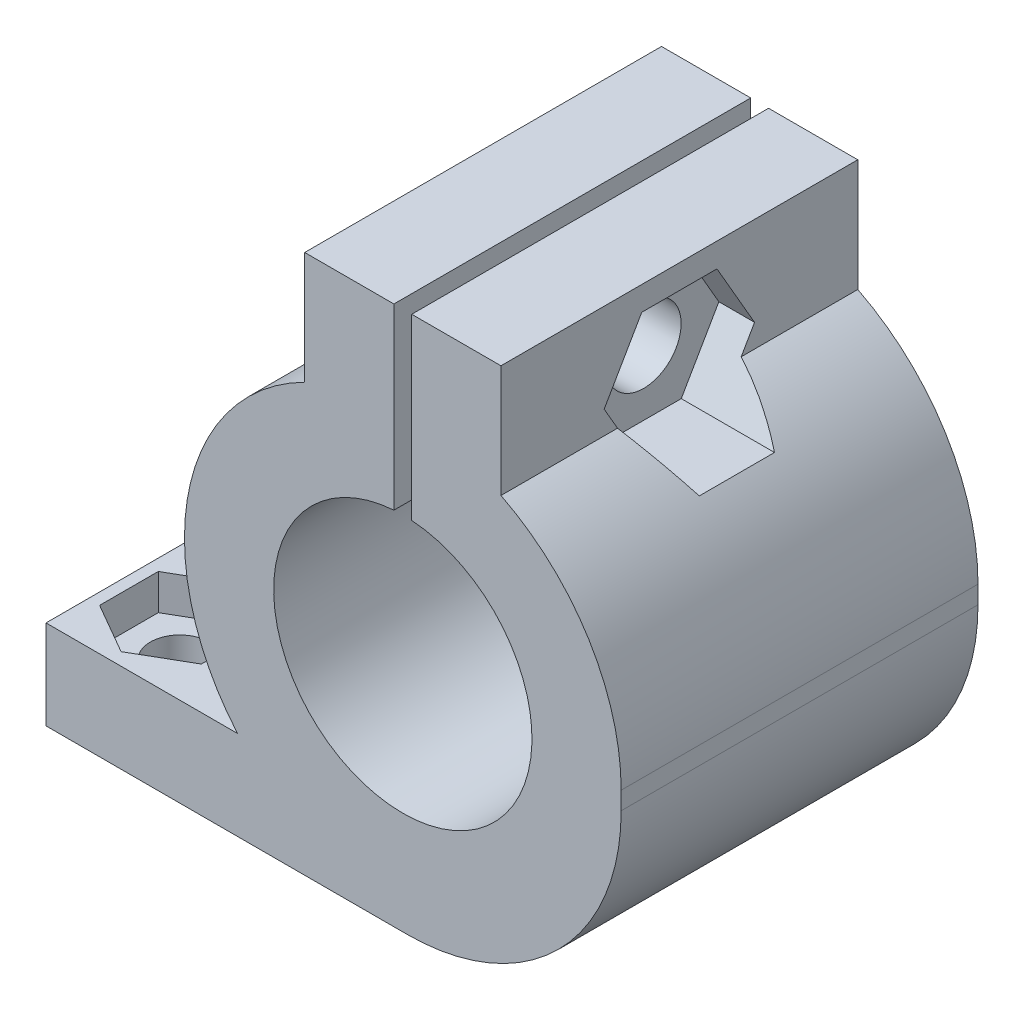
from build123d import *

# Parameters (mm, degrees)
BOSS_EXTRUDE1_DEPTH     = 20
SKETCH2_R               = 2.1
CUT_EXTRUDE1_DEPTH      = 15.5
CUT_EXTRUDE1_DEPTH_BACK = 18.739
SKETCH4_R               = 3.65
CUT_EXTRUDE2_DEPTH      = 15.5
CUT_EXTRUDE2_DEPTH_BACK = 2
CUT_EXTRUDE3_DEPTH      = 7.7390001
CUT_EXTRUDE3_DEPTH_BACK = 2
SKETCH6_R               = 1.65
CUT_EXTRUDE4_DEPTH      = 6
CUT_EXTRUDE5_DEPTH      = 2
FILLET1_R               = 12


with BuildPart() as part:
    # Sketch1 → Boss-Extrude1 (new body)
    with BuildSketch(Plane.XY):
        with BuildLine():
            Line((-0.5, 7.221711778), (-0.5, 17.231747474))
            Line((-0.5, 17.231747474), (-5.5, 17.231747474))
            Line((-5.5, 17.231747474), (-5.5, 10.933577685))
            ThreePointArc((-5.5, 10.933577685), (-12.004275475, 2.385475074), (-9.262457611, -8))
            Line((-9.262457611, -8), (-20, -8))
            Line((-20, -8), (-20, -13))
            Line((-20, -13), (12.239, -13))
            Line((12.239, -13), (12.239, 0))
            ThreePointArc((12.239, 0), (10.418915994, 6.421784059), (5.5, 10.933577685))
            Line((5.5, 10.933577685), (5.5, 17.231747474))
            Line((5.5, 17.231747474), (0.5, 17.231747474))
            Line((0.5, 17.231747474), (0.5, 7.221711778))
            ThreePointArc((0.5, 7.221711778), (0, -7.239), (-0.5, 7.221711778))
        make_face()
    extrude(amount=BOSS_EXTRUDE1_DEPTH)

    # Sketch2 → Cut-Extrude1 (cut, two sides)
    with BuildSketch(Plane.ZY.offset(5.5)) as cut_extrude1_sk:
        with Locations((10, 12.231747474)):
            Circle(SKETCH2_R)
    extrude(amount=CUT_EXTRUDE1_DEPTH, mode=Mode.SUBTRACT)
    extrude(cut_extrude1_sk.sketch, amount=-CUT_EXTRUDE1_DEPTH_BACK, mode=Mode.SUBTRACT)

    # Sketch4 → Cut-Extrude2 (cut, two sides)
    with BuildSketch(Plane.ZY.offset(5.5)) as cut_extrude2_sk:
        with Locations((10, 12.231747474)):
            Circle(SKETCH4_R)
    extrude(amount=CUT_EXTRUDE2_DEPTH, mode=Mode.SUBTRACT)
    extrude(cut_extrude2_sk.sketch, amount=-CUT_EXTRUDE2_DEPTH_BACK, mode=Mode.SUBTRACT)

    # Sketch5 → Cut-Extrude3 (cut, two sides)
    with BuildSketch(Plane(origin=(5.5, 0, 0), x_dir=(0, 0, -1), z_dir=(1, 0, 0))) as cut_extrude3_sk:
        Polygon((-12.107328483, 8.581747474), (-14.214656965, 12.231747474), (-12.107328483, 15.881747474), (-7.892671517, 15.881747474), (-5.785343035, 12.231747474), (-7.892671517, 8.581747474), align=None)
    extrude(amount=CUT_EXTRUDE3_DEPTH, mode=Mode.SUBTRACT)
    extrude(cut_extrude3_sk.sketch, amount=-CUT_EXTRUDE3_DEPTH_BACK, mode=Mode.SUBTRACT)

    # Sketch6 → Cut-Extrude4 (cut, through all)
    with BuildSketch(Plane(origin=(0, -8, 0), x_dir=(1, 0, 0), z_dir=(0, 1, 0))):
        with Locations((-16.5, -4)):
            Circle(SKETCH6_R)
        with Locations((-16.5, -16)):
            Circle(SKETCH6_R)
    extrude(amount=-CUT_EXTRUDE4_DEPTH, mode=Mode.SUBTRACT)

    # Sketch7 → Cut-Extrude5 (cut)
    with BuildSketch(Plane(origin=(0, -8, 0), x_dir=(1, 0, 0), z_dir=(0, 1, 0))):
        Polygon((-16.5, -7.290896534), (-13.65, -5.645448267), (-13.65, -2.354551733), (-16.5, -0.709103466), (-19.35, -2.354551733), (-19.35, -5.645448267), align=None)
        Polygon((-16.5, -12.709103466), (-19.35, -14.354551733), (-19.35, -17.645448267), (-16.5, -19.290896534), (-13.65, -17.645448267), (-13.65, -14.354551733), align=None)
    extrude(amount=-CUT_EXTRUDE5_DEPTH, mode=Mode.SUBTRACT)

    # Fillet1
    fillet1_edges = [part.edges().sort_by_distance(p)[0] for p in [
        (12.239, -13, 10),
    ]]
    fillet(fillet1_edges, radius=FILLET1_R)


solid = part.part
